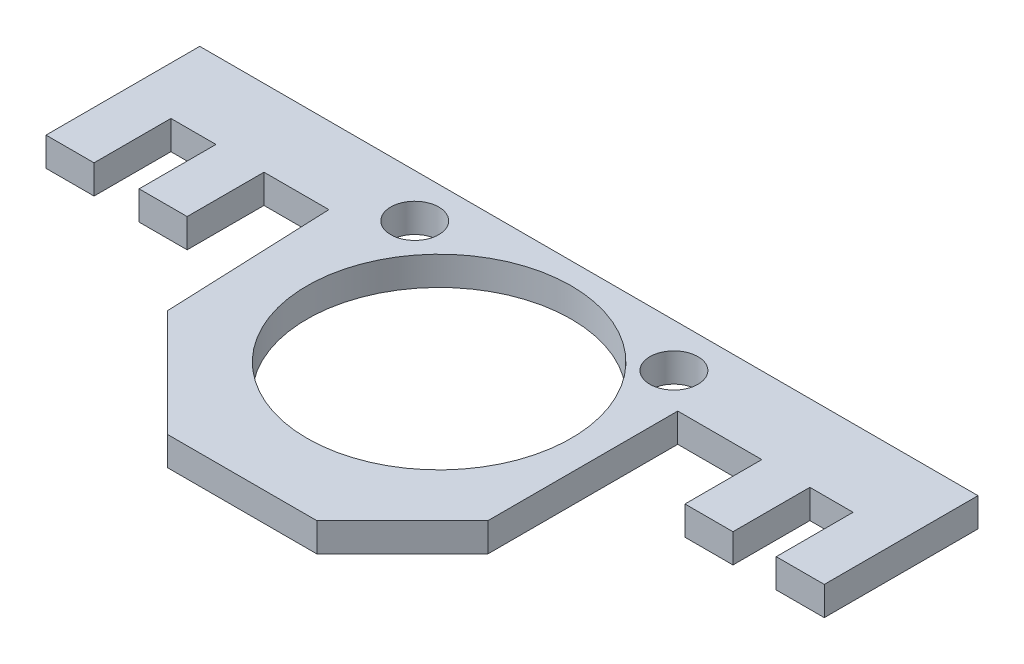
from build123d import *

# Parameters (mm, degrees)
BOSS_EXTRUDE1_DEPTH = 1.2
CUT_EXTRUDE2_REACH  = 3.2
SKETCH3_R           = 1
SKETCH3_R_2         = 5.5


with BuildPart() as part:
    # Sketch1 → Boss-Extrude1 (new body)
    with BuildSketch(Plane(origin=(0, 0, 0), x_dir=(1, 0, 0), z_dir=(0, 1, 0))):
        Polygon((-54.589869364, 21.700331248), (-22.189869364, 21.700331248), (-22.189869364, 15.300331248), (-24.189869364, 15.300331248), (-24.189869364, 18.500331248), (-25.989869364, 18.500331248), (-25.989869364, 15.300331248), (-27.989869364, 15.300331248), (-27.989869364, 18.500331248), (-31.489869364, 18.500331248), (-31.489869364, 10.600331248), (-35.053687541, 7.036513071), (-41.273687541, 7.036513071), (-45.728460263, 11.491285792), (-46.013981929, 18.500331248), (-48.713981929, 18.500331248), (-48.713981929, 15.300331248), (-50.713981929, 15.300331248), (-50.713981929, 18.500331248), (-52.589869364, 18.500331248), (-52.589869364, 15.300331248), (-54.589869364, 15.300331248), align=None)
    extrude(amount=BOSS_EXTRUDE1_DEPTH)

    # Sketch3 → Cut-Extrude2 (cut, up to next)
    with BuildSketch(Plane(origin=(0, 1.2, 0), x_dir=(1, 0, 0), z_dir=(0, 1, 0)), mode=Mode.PRIVATE) as cut_extrude2_sk1:
        with Locations((-43.822096549, 19.883607228)):
            Circle(SKETCH3_R)
    cut_extrude2_tool1 = extrude(cut_extrude2_sk1.sketch, amount=-CUT_EXTRUDE2_REACH, mode=Mode.PRIVATE) & part.part
    add(cut_extrude2_tool1.solids().sort_by_distance((-43.822097, 1.2, -19.883607))[0], mode=Mode.SUBTRACT)
    # Sketch3 → Cut-Extrude2 (cut, up to next)
    with BuildSketch(Plane(origin=(0, 1.2, 0), x_dir=(1, 0, 0), z_dir=(0, 1, 0)), mode=Mode.PRIVATE) as cut_extrude2_sk2:
        with Locations((-33.032153908, 19.883607228)):
            Circle(SKETCH3_R)
    cut_extrude2_tool2 = extrude(cut_extrude2_sk2.sketch, amount=-CUT_EXTRUDE2_REACH, mode=Mode.PRIVATE) & part.part
    add(cut_extrude2_tool2.solids().sort_by_distance((-33.032154, 1.2, -19.883607))[0], mode=Mode.SUBTRACT)
    # Sketch3 → Cut-Extrude2 (cut, up to next)
    with BuildSketch(Plane(origin=(0, 1.2, 0), x_dir=(1, 0, 0), z_dir=(0, 1, 0)), mode=Mode.PRIVATE) as cut_extrude2_sk3:
        with Locations((-38.224033721, 15.300331248)):
            Circle(SKETCH3_R_2)
    cut_extrude2_tool3 = extrude(cut_extrude2_sk3.sketch, amount=-CUT_EXTRUDE2_REACH, mode=Mode.PRIVATE) & part.part
    add(cut_extrude2_tool3.solids().sort_by_distance((-38.224034, 1.2, -15.300331))[0], mode=Mode.SUBTRACT)


solid = part.part
